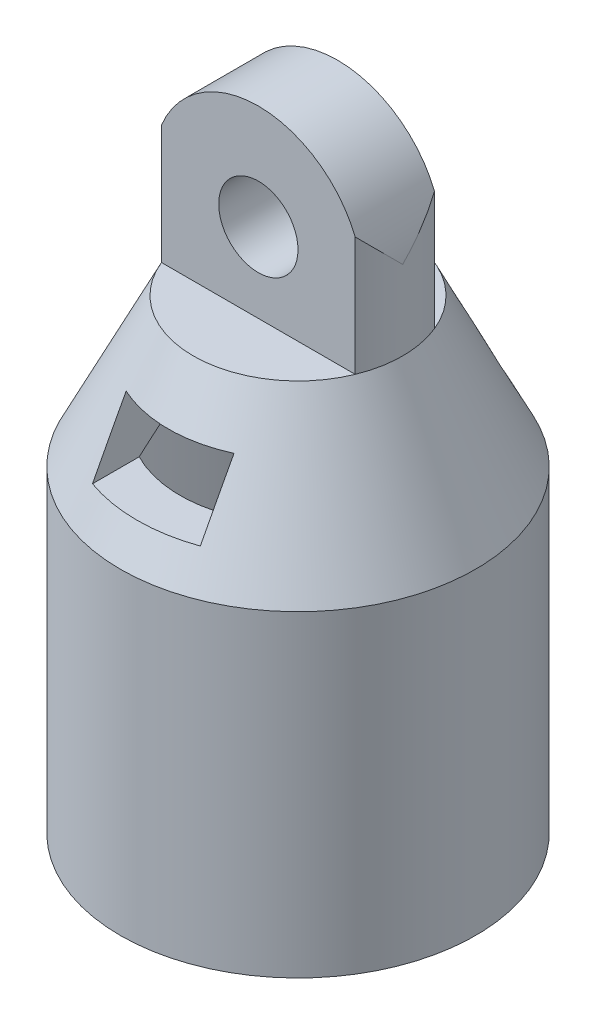
from build123d import *

# Parameters (mm, degrees)
SKETCH1_R           = 7.112
SKETCH1_R_2         = 6.096
BOSS_EXTRUDE1_DEPTH = 12.7
SKETCH3_R           = 1.5875
BOSS_EXTRUDE3_DEPTH = 1.5875
CUT_EXTRUDE1_DEPTH  = 12.7
SKETCH5_OUTSIDE_W   = 22.798
SKETCH5_OUTSIDE_H   = 22.798
SKETCH5_OUTSIDE_R   = 4.191
CUT_EXTRUDE3_DEPTH  = 25.4


with BuildPart() as part:
    # Sketch1 → Boss-Extrude1 (new body)
    with BuildSketch(Plane(origin=(0, 0, 0), x_dir=(1, 0, 0), z_dir=(0, 1, 0))):
        Circle(SKETCH1_R)
        Circle(SKETCH1_R_2, mode=Mode.SUBTRACT)
    extrude(amount=BOSS_EXTRUDE1_DEPTH)

    # Sketch2 → Revolve2 (revolve)
    with BuildSketch(Plane.XY):
        Polygon((-7.112, 12.7), (-6.096, 12.7), (-2.159, 16.601959342), (0, 16.601959342), (0, 18.633959342), (-4.191, 18.633959342), align=None)
    revolve(axis=Axis((0, 16.601959342, 0), (0, 1, 0)))

    # Sketch3 → Boss-Extrude3 (add, symmetric)
    with BuildSketch(Plane.XY):
        with BuildLine():
            Line((-4.191, 18.633959342), (-4.191, 21.808959342))
            ThreePointArc((-4.191, 21.808959342), (0, 25.999959342), (4.191, 21.808959342))
            Line((4.191, 21.808959342), (4.191, 18.633959342))
            Line((4.191, 18.633959342), (-4.191, 18.633959342))
        make_face()
        with Locations((0, 21.808959342)):
            Circle(SKETCH3_R, mode=Mode.SUBTRACT)
    extrude(amount=BOSS_EXTRUDE3_DEPTH, both=True)

    # Sketch4 → Cut-Extrude1 (cut, symmetric)
    with BuildSketch(Plane.XY):
        Polygon((0, 16.601959342), (2.159, 16.601959342), (2.159, 14.061959342), (-2.159, 14.061959342), (-2.159, 16.601959342), align=None)
    extrude(amount=CUT_EXTRUDE1_DEPTH, both=True, mode=Mode.SUBTRACT)

    # Sketch5 outside → Cut-Extrude3 (cut)
    with BuildSketch(Plane.XZ.offset(-18.633959342)):
        Rectangle(SKETCH5_OUTSIDE_W, SKETCH5_OUTSIDE_H)
        Circle(SKETCH5_OUTSIDE_R, mode=Mode.SUBTRACT)
    extrude(amount=-CUT_EXTRUDE3_DEPTH, mode=Mode.SUBTRACT)


solid = part.part
